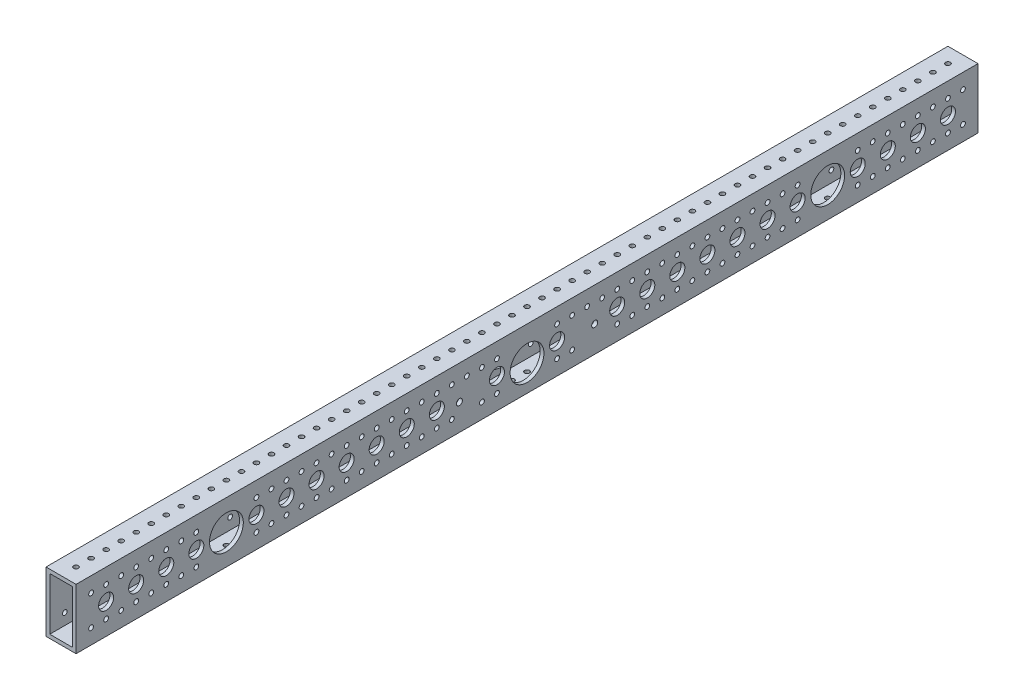
from build123d import *

# Parameters (mm, degrees)
SKETCH1_W                                           = 25.4
SKETCH1_H                                           = 50.8
BOSS_EXTRUDE1_DEPTH                                 = 762
SHELL1_T                                            = -3.175
F_21_0_159_DIAMETER_HOLE1_D                         = 4.0386
LPATTERN1_COUNT                                     = 59
LPATTERN1_PITCH                                     = 12.7
F_21_0_159_DIAMETER_HOLE2_D                         = 4.0386
LPATTERN2_COUNT                                     = 59
LPATTERN2_PITCH                                     = 12.7
LPATTERN2_COUNT_DIR2                                = 2
LPATTERN2_PITCH_DIR2                                = 25.4
F_1_2_0_5_DIAMETER_HOLE1_D                          = 12.7
LPATTERN3_COUNT                                     = 29
LPATTERN3_PITCH                                     = 25.4
F_1_2_1_125_DIAMETER_HOLE1_D                        = 28.575
CBORE_FOR_00_BINDING_HEAD_MACHINE_SCREW_D           = 5.1054
CBORE_FOR_00_BINDING_HEAD_MACHINE_SCREW_CBORE_D     = 15.875
CBORE_FOR_00_BINDING_HEAD_MACHINE_SCREW_CBORE_DEPTH = 3.175


with BuildPart() as part:
    # Sketch1 → Boss-Extrude1 (new body)
    with BuildSketch(Plane.XY):
        Rectangle(SKETCH1_W, SKETCH1_H)
    extrude(amount=BOSS_EXTRUDE1_DEPTH)

    # Shell1
    shell1_openings = [part.faces().sort_by_distance(p)[0] for p in [
        (0, 0, 762),
        (0, 0, 0),
    ]]
    offset(amount=SHELL1_T, openings=shell1_openings, kind=Kind.INTERSECTION)

    # #21 (0.159) Diameter Hole1 (through all)
    with Locations(Plane(origin=(0, 25.4, 0), x_dir=(1, 0, 0), z_dir=(0, 1, 0))):
        with Locations((0, -12.7)):
            f_21_0_159_diameter_hole1 = Hole(F_21_0_159_DIAMETER_HOLE1_D / 2)

    # LPattern1: #21 (0.159) Diameter Hole1 ×59
    with Locations(*[(0, 0, i * LPATTERN1_PITCH) for i in range(1, LPATTERN1_COUNT)]):
        add(f_21_0_159_diameter_hole1, mode=Mode.SUBTRACT)

    # #21 (0.159) Diameter Hole2 (through all)
    with Locations(Plane.ZY.offset(12.7)):
        with Locations((12.7, 12.7)):
            f_21_0_159_diameter_hole2 = Hole(F_21_0_159_DIAMETER_HOLE2_D / 2)

    # LPattern2: 21 _0.159_ Diameter Hole2 59 × 2, 21 skipped
    with Locations(*[(0, -j * LPATTERN2_PITCH_DIR2, i * LPATTERN2_PITCH) for i in range(LPATTERN2_COUNT) for j in range(LPATTERN2_COUNT_DIR2) if (i, j) not in ((0, 0), (8, 0), (8, 1), (9, 0), (9, 1), (10, 0), (10, 1), (24, 1), (25, 1), (28, 0), (28, 1), (29, 0), (29, 1), (30, 0), (30, 1), (33, 1), (48, 0), (48, 1), (49, 0), (49, 1), (50, 0), (50, 1))]):
        add(f_21_0_159_diameter_hole2, mode=Mode.SUBTRACT)

    # 1/2 (0.5) Diameter Hole1 (through all)
    with Locations(Plane.ZY.offset(12.7)):
        with Locations((25.4, 0)):
            f_1_2_0_5_diameter_hole1 = Hole(F_1_2_0_5_DIAMETER_HOLE1_D / 2)

    # LPattern3: 1/2 (0.5) Diameter Hole1 ×29, 5 skipped
    with Locations(*[(0, 0, i * LPATTERN3_PITCH) for i in range(1, LPATTERN3_COUNT) if i not in (4, 12, 14, 16, 24)]):
        add(f_1_2_0_5_diameter_hole1, mode=Mode.SUBTRACT)

    # 1/2 (1.125) Diameter Hole1 (through all)
    with Locations(Plane.ZY.offset(12.7)):
        with Locations((127, 0), (381, -3.175), (635, 0)):
            Hole(F_1_2_1_125_DIAMETER_HOLE1_D / 2)

    # CBORE for #00 Binding Head Machine Screw1 (through all)
    with Locations(Plane.ZY.offset(12.7)):
        with Locations((323.85, -3.175), (438.15, -3.175)):
            CounterBoreHole(CBORE_FOR_00_BINDING_HEAD_MACHINE_SCREW_D / 2, CBORE_FOR_00_BINDING_HEAD_MACHINE_SCREW_CBORE_D / 2, CBORE_FOR_00_BINDING_HEAD_MACHINE_SCREW_CBORE_DEPTH)


solid = part.part
